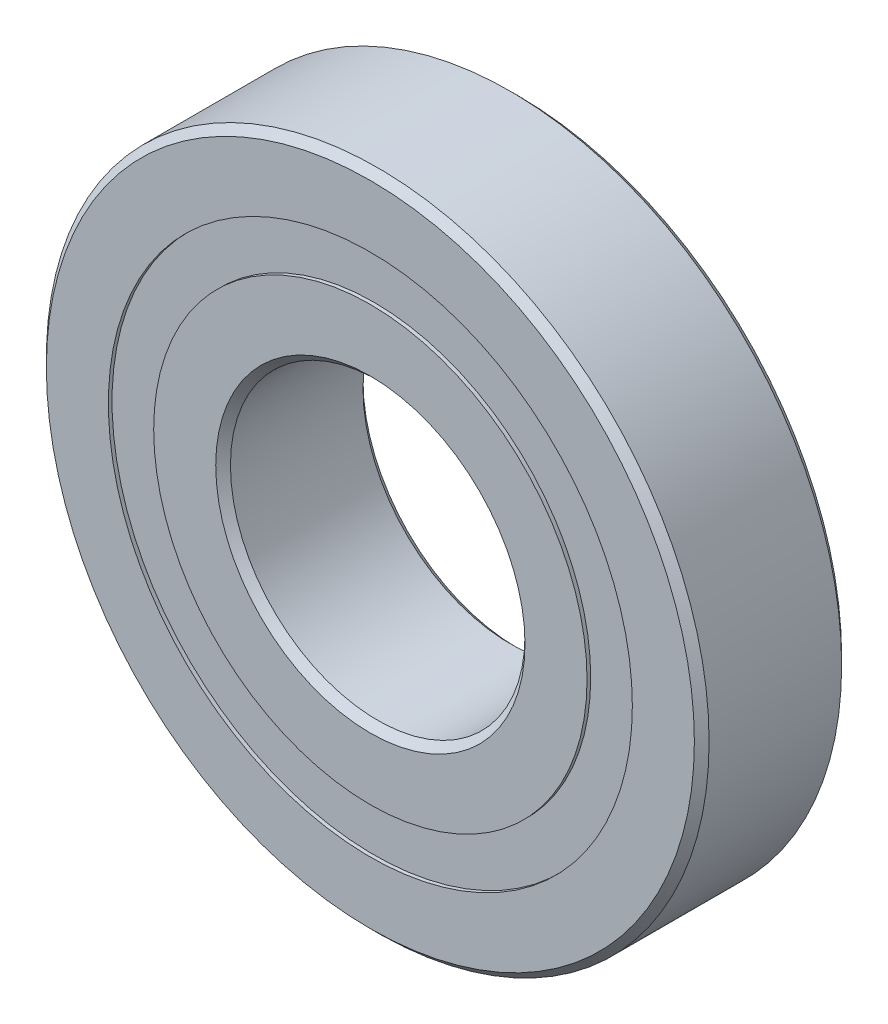
from build123d import *

# Parameters (mm, degrees)
CIRPATTERN1_COUNT = 10
SKETCH5_W         = 1.299971099
SKETCH5_H         = 1.953846154


with BuildPart() as part:
    # Sketch1 → Revolve1 (revolve)
    with BuildSketch(Plane(origin=(0, 0, 0), x_dir=(0, 0, -1), z_dir=(1, 0, 0))):
        with BuildLine():
            Line((2.8575, 14.2875), (-2.8575, 14.2875))
            Line((-2.8575, 14.2875), (-3.175, 13.97))
            Line((-3.175, 13.97), (-3.175, 11.295673077))
            Line((-3.175, 11.295673077), (-1.411111111, 11.295673077))
            ThreePointArc((-1.411111111, 11.295673077), (0, 12.035028901), (1.411111111, 11.295673077))
            Line((1.411111111, 11.295673077), (3.175, 11.295673077))
            Line((3.175, 11.295673077), (3.175, 13.97))
            Line((3.175, 13.97), (2.8575, 14.2875))
        make_face()
    revolve(axis=Axis((0, 0, 3.175), (0, 0, -1)))


with BuildPart() as body_2:
    # Sketch3 → Revolve3 (revolve)
    with BuildSketch(Plane(origin=(0, 0, 0), x_dir=(0, 0, -1), z_dir=(1, 0, 0))):
        with BuildLine():
            Line((-3.175, 9.341826923), (-1.411111111, 9.341826923))
            ThreePointArc((-1.411111111, 9.341826923), (0, 8.602471099), (1.411111111, 9.341826923))
            Line((1.411111111, 9.341826923), (3.175, 9.341826923))
            Line((3.175, 9.341826923), (3.175, 6.6675))
            Line((3.175, 6.6675), (2.8575, 6.35))
            Line((2.8575, 6.35), (-2.8575, 6.35))
            Line((-2.8575, 6.35), (-3.175, 6.6675))
            Line((-3.175, 6.6675), (-3.175, 9.341826923))
        make_face()
    revolve(axis=Axis((0, 0, 3.175), (0, 0, -1)))


with BuildPart() as body_3:
    # Sketch4 → Revolve4 (revolve)
    with BuildSketch(Plane(origin=(0, 0, 0), x_dir=(0, 0, -1), z_dir=(1, 0, 0))):
        with BuildLine():
            Line((-1.716278901, 10.31875), (1.716278901, 10.31875))
            ThreePointArc((1.716278901, 10.31875), (0, 12.035028901), (-1.716278901, 10.31875))
        make_face()
    revolve(axis=Axis((0, 10.31875, 1.716278901), (0, 0, -1)))


with BuildPart() as cirpattern1_1:
    # CirPattern1: pattern copy
    add(body_3.part.rotate(Axis((0, 0, -3.175), (0, 0, 1)), 1 * 360 / CIRPATTERN1_COUNT))


with BuildPart() as cirpattern1_2:
    # CirPattern1: pattern copy
    add(body_3.part.rotate(Axis((0, 0, -3.175), (0, 0, 1)), 2 * 360 / CIRPATTERN1_COUNT))


with BuildPart() as cirpattern1_3:
    # CirPattern1: pattern copy
    add(body_3.part.rotate(Axis((0, 0, -3.175), (0, 0, 1)), 3 * 360 / CIRPATTERN1_COUNT))


with BuildPart() as cirpattern1_4:
    # CirPattern1: pattern copy
    add(body_3.part.rotate(Axis((0, 0, -3.175), (0, 0, 1)), 4 * 360 / CIRPATTERN1_COUNT))


with BuildPart() as cirpattern1_5:
    # CirPattern1: pattern copy
    add(body_3.part.rotate(Axis((0, 0, -3.175), (0, 0, 1)), 5 * 360 / CIRPATTERN1_COUNT))


with BuildPart() as cirpattern1_6:
    # CirPattern1: pattern copy
    add(body_3.part.rotate(Axis((0, 0, -3.175), (0, 0, 1)), 6 * 360 / CIRPATTERN1_COUNT))


with BuildPart() as cirpattern1_7:
    # CirPattern1: pattern copy
    add(body_3.part.rotate(Axis((0, 0, -3.175), (0, 0, 1)), 7 * 360 / CIRPATTERN1_COUNT))


with BuildPart() as cirpattern1_8:
    # CirPattern1: pattern copy
    add(body_3.part.rotate(Axis((0, 0, -3.175), (0, 0, 1)), 8 * 360 / CIRPATTERN1_COUNT))


with BuildPart() as cirpattern1_9:
    # CirPattern1: pattern copy
    add(body_3.part.rotate(Axis((0, 0, -3.175), (0, 0, 1)), 9 * 360 / CIRPATTERN1_COUNT))


with BuildPart() as body_13:
    # Sketch5 → Revolve5 (revolve)
    with BuildSketch(Plane(origin=(0, 0, 0), x_dir=(0, 0, -1), z_dir=(1, 0, 0))):
        with Locations((-2.366264451, 10.31875)):
            Rectangle(SKETCH5_W, SKETCH5_H)
        with Locations((2.366264451, 10.31875)):
            Rectangle(SKETCH5_W, SKETCH5_H)
    revolve(axis=Axis((0, 0, 3.175), (0, 0, -1)))


solid = Compound([part.part, body_2.part, body_3.part, cirpattern1_1.part, cirpattern1_2.part, cirpattern1_3.part, cirpattern1_4.part, cirpattern1_5.part, cirpattern1_6.part, cirpattern1_7.part, cirpattern1_8.part, cirpattern1_9.part, body_13.part])
